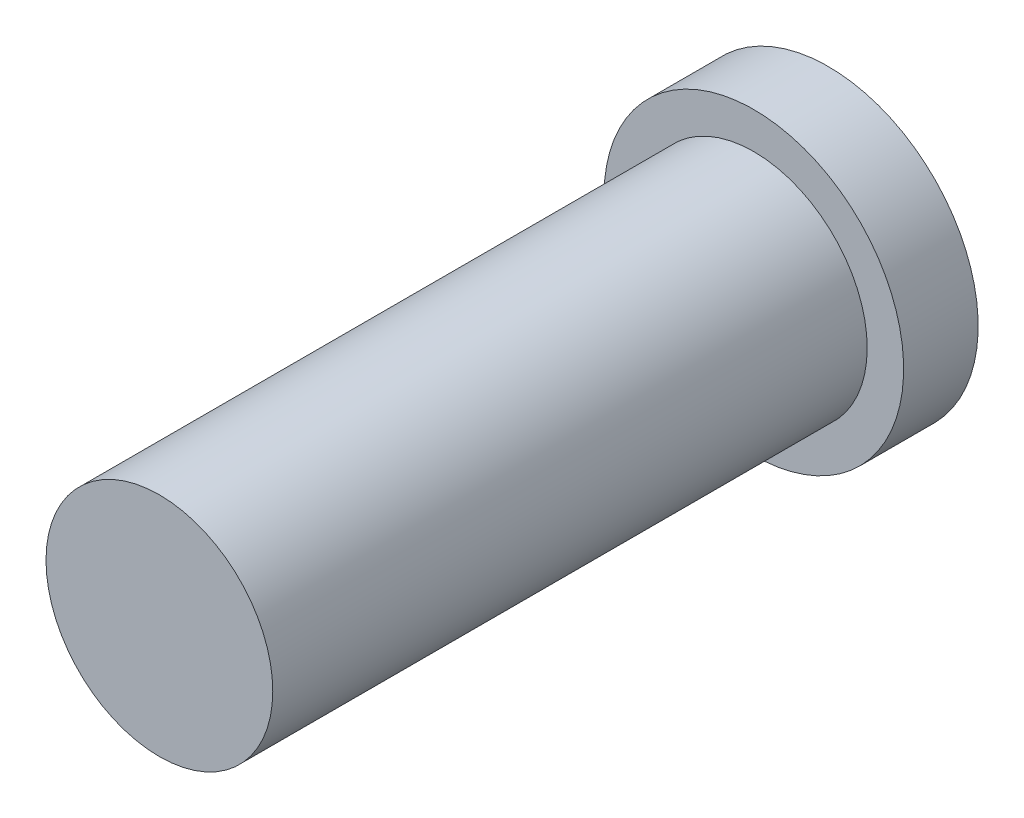
from build123d import *

# Parameters (mm, degrees)
SKETCH1_R           = 0.7
BOSS_EXTRUDE1_DEPTH = 3.67
SKETCH2_R           = 0.925
BOSS_EXTRUDE2_DEPTH = 0.46
SKETCH3_R           = 0.455
CUT_EXTRUDE1_DEPTH  = 3.5


with BuildPart() as part:
    # Sketch1 → Boss-Extrude1 (new body)
    with BuildSketch(Plane.XY):
        Circle(SKETCH1_R)
    extrude(amount=BOSS_EXTRUDE1_DEPTH)

    # Sketch2 → Boss-Extrude2 (add)
    with BuildSketch(Plane(origin=(0, 0, 0), x_dir=(-1, 0, 0), z_dir=(0, 0, -1))):
        Circle(SKETCH2_R)
    extrude(amount=BOSS_EXTRUDE2_DEPTH)

    # Sketch3 → Cut-Extrude1 (cut)
    with BuildSketch(Plane(origin=(0, 0, -0.46), x_dir=(-1, 0, 0), z_dir=(0, 0, -1))):
        Circle(SKETCH3_R)
    extrude(amount=-CUT_EXTRUDE1_DEPTH, mode=Mode.SUBTRACT)


solid = part.part
